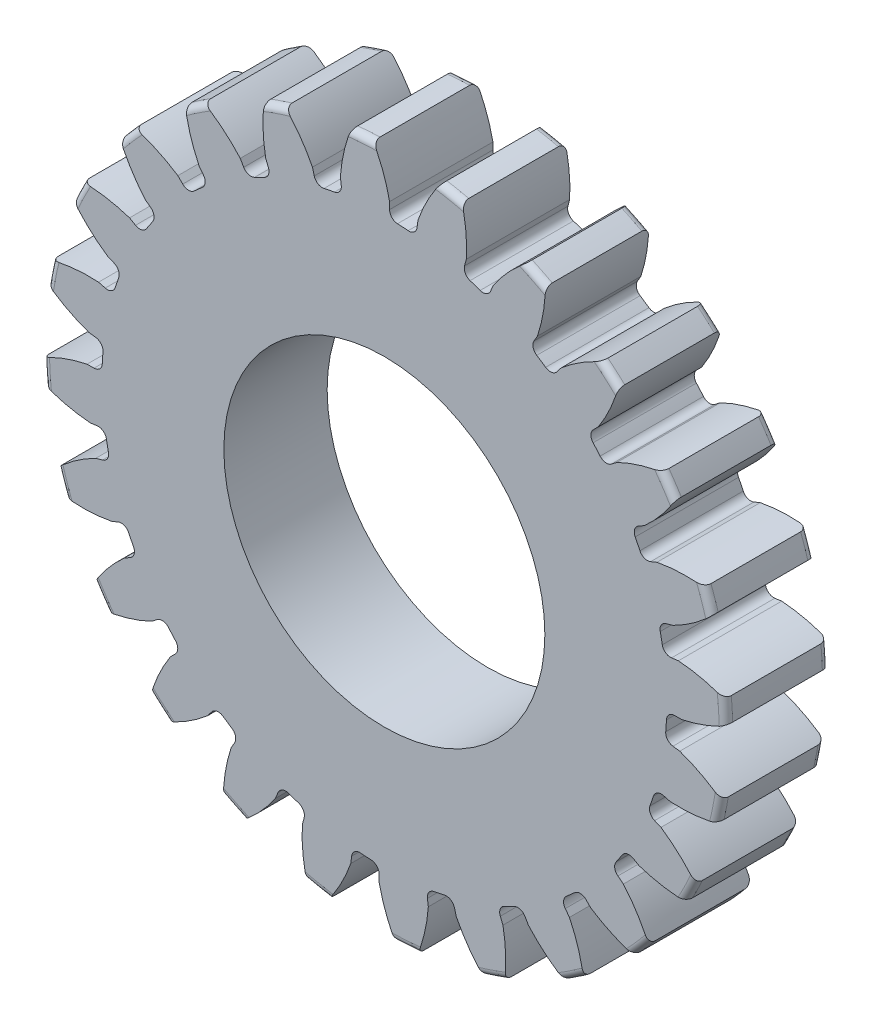
from build123d import *

# Parameters (mm, degrees)
SKETCH1_R                = 13.716
BOSS_EXTRUDE1_DEPTH      = 4.14693862
SKETCH2_W                = 6.3373
SKETCH2_H                = 6.35
FILLET2_R                = 0.27432
CUT_EXTRUDE1_DEPTH       = 23.348666063
FILLET1_R                = 0.332486
CIRPATTERN1_COUNT        = 24
FILLET1_OF_CIRPATTERN1_R = 0.332486
SKETCH5_R                = 3.175
CUT_EXTRUDE2_DEPTH       = 23.339624524
CHAMFER1_SIZE            = 0.3175
SKETCH8_W                = 6.35
SKETCH8_H                = 1.7526
CUT_SWEEP1_PITCH         = 0.79375
CUT_SWEEP1_HEIGHT        = 6.35
CUT_SWEEP1_RADIUS        = 1.7526
SKETCH12_W               = 1.7526
SKETCH12_H               = 3.175
CHAMFER3_SIZE            = 0.280416
CUT_SWEEP2_PITCH         = 0.79375
CUT_SWEEP2_HEIGHT        = 3.96875
CUT_SWEEP2_RADIUS        = 1.7526
CUT_EXTRUDE4_DEPTH       = 2.032
SKETCH19_R               = 8.586315629
CUT_EXTRUDE7_DEPTH       = 6.95286138
SKETCH20_R               = 8.250795243
CUT_EXTRUDE8_DEPTH       = 6.95286138
SKETCH21_R               = 6.442565601
CUT_EXTRUDE9_DEPTH       = 4.14693862
SCALE1_SCALE             = 1.75


with BuildPart() as part:
    # Sketch1 → Boss-Extrude1 (new body)
    with BuildSketch(Plane.XY):
        Circle(SKETCH1_R)
    extrude(amount=-BOSS_EXTRUDE1_DEPTH)

    # Fillet2
    fillet2_edges = [part.edges().sort_by_distance(p)[0] for p in [
        (-13.716, 0, 0),
        (-13.716, 0, -4.14693862),
    ]]
    fillet(fillet2_edges, radius=FILLET2_R)

    # Sketch4 → Cut-Extrude1 (cut, through all)
    with BuildSketch(Plane.XY):
        with BuildLine():
            Line((0.210191388, 11.932245124), (0.210191388, 11.33280094))
            ThreePointArc((0.210191388, 11.33280094), (0.74132985, 11.310481317), (1.27083763, 11.263282349))
            Line((1.27083763, 11.263282349), (1.349080978, 11.857598181))
            add(Edge.make_bspline(
                [(5.307200939, 15.849419331), (2.291771979, 14.546050899), (1.349080978, 11.857598181)],
                knots=[0, 0, 0, 1, 1, 1], degree=2))
            ThreePointArc((5.307200939, 15.849419331), (1.093175261, 16.67859235), (-3.193027723, 16.406555059))
            add(Edge.make_bspline(
                [(-3.193027723, 16.406555059), (-0.37352041, 14.720743801), (0.210191388, 11.932245124)],
                knots=[0, 0, 0, 1, 1, 1], degree=2))
        make_face()
    cut_extrude1 = extrude(amount=-CUT_EXTRUDE1_DEPTH, mode=Mode.SUBTRACT)

    # Fillet1
    fillet1_edges = [part.edges().sort_by_distance(p)[0] for p in [
        (1.27083763, 11.263282349, -2.07346931),
        (0.210191388, 11.33280094, -2.07346931),
    ]]
    fillet(fillet1_edges, radius=FILLET1_R)

    # CirPattern1: Cut-Extrude1 ×24 about axis
    cirpattern1_axis = Axis((0, 0, -4.14693862), (0, 0, 1))
    for i in range(1, CIRPATTERN1_COUNT):
        add(cut_extrude1.rotate(cirpattern1_axis, i * 360 / CIRPATTERN1_COUNT), mode=Mode.SUBTRACT)

    # Fillet1 of CirPattern1
    fillet1_of_cirpattern1_edges = [part.edges().sort_by_distance(p)[0] for p in [
        (-1.687617095, 11.208412292, -2.07346931),
        (-2.730115427, 11.001046646, -2.07346931),
        (-4.531063503, 10.389707459, -2.07346931),
        (-5.484369388, 9.919589204, -2.07346931),
        (-7.065725422, 8.862961233, -2.07346931),
        (-7.864872638, 8.162128151, -2.07346931),
        (-9.11886983, 6.732218846, -2.07346931),
        (-9.709397816, 5.848431552, -2.07346931),
        (-10.550578328, 4.14268687, -2.07346931),
        (-10.892243578, 3.136174008, -2.07346931),
        (-11.263282349, 1.27083763, -2.07346931),
        (-11.33280094, 0.210191388, -2.07346931),
        (-11.208412292, -1.687617095, -2.07346931),
        (-11.001046646, -2.730115427, -2.07346931),
        (-10.389707459, -4.531063503, -2.07346931),
        (-9.919589204, -5.484369388, -2.07346931),
        (-8.862961233, -7.065725422, -2.07346931),
        (-8.162128151, -7.864872638, -2.07346931),
        (-6.732218846, -9.11886983, -2.07346931),
        (-5.848431552, -9.709397816, -2.07346931),
        (-4.14268687, -10.550578328, -2.07346931),
        (-3.136174008, -10.892243578, -2.07346931),
        (-1.27083763, -11.263282349, -2.07346931),
        (-0.210191388, -11.33280094, -2.07346931),
        (1.687617095, -11.208412292, -2.07346931),
        (2.730115427, -11.001046646, -2.07346931),
        (4.531063503, -10.389707459, -2.07346931),
        (5.484369388, -9.919589204, -2.07346931),
        (7.065725422, -8.862961233, -2.07346931),
        (7.864872638, -8.162128151, -2.07346931),
        (9.11886983, -6.732218846, -2.07346931),
        (9.709397816, -5.848431552, -2.07346931),
        (10.550578328, -4.14268687, -2.07346931),
        (10.892243578, -3.136174008, -2.07346931),
        (11.263282349, -1.27083763, -2.07346931),
        (11.33280094, -0.210191388, -2.07346931),
        (11.208412292, 1.687617095, -2.07346931),
        (11.001046646, 2.730115427, -2.07346931),
        (10.389707459, 4.531063503, -2.07346931),
        (9.919589204, 5.484369388, -2.07346931),
        (8.862961233, 7.065725422, -2.07346931),
        (8.162128151, 7.864872638, -2.07346931),
        (6.732218846, 9.11886983, -2.07346931),
        (5.848431552, 9.709397816, -2.07346931),
        (4.14268687, 10.550578328, -2.07346931),
        (3.136174008, 10.892243578, -2.07346931),
    ]]
    fillet(fillet1_of_cirpattern1_edges, radius=FILLET1_OF_CIRPATTERN1_R)

    # Sketch5 → Cut-Extrude2 (cut, through all)
    with BuildSketch(Plane.XY):
        Circle(SKETCH5_R)
    extrude(amount=-CUT_EXTRUDE2_DEPTH, mode=Mode.SUBTRACT)


with BuildPart() as body_2:
    # Sketch2 → Revolve1 (revolve)
    with BuildSketch(Plane(origin=(0, 0, 0), x_dir=(0, 0, -1), z_dir=(1, 0, 0)), mode=Mode.PRIVATE) as revolve1_sk:
        with Locations((7.93115, 3.175)):
            Rectangle(SKETCH2_W, SKETCH2_H)
    revolve(revolve1_sk.sketch.rotate(Axis((0, 0, -4.7625), (0, 0, -1)), 90), axis=Axis((0, 0, -4.7625), (0, 0, -1)))

    # Chamfer1
    chamfer1_edges = [body_2.edges().sort_by_distance(p)[0] for p in [
        (-6.35, 0, -11.0998),
    ]]
    chamfer(chamfer1_edges, length=CHAMFER1_SIZE)

    # Sketch20 → Cut-Extrude8 (cut)
    with BuildSketch(Plane(origin=(0, 0, -11.0998), x_dir=(-1, 0, 0), z_dir=(0, 0, -1))):
        Circle(SKETCH20_R)
    extrude(amount=-CUT_EXTRUDE8_DEPTH, mode=Mode.SUBTRACT)


with BuildPart() as body_3:
    # Sketch8 → Revolve2 (revolve)
    with BuildSketch(Plane(origin=(0, 0, 0), x_dir=(0, -1, 0), z_dir=(1, 0, 0)), mode=Mode.PRIVATE) as revolve2_sk:
        with Locations((-3.175, 8.6487)):
            Rectangle(SKETCH8_W, SKETCH8_H)
    revolve(revolve2_sk.sketch.rotate(Axis((0, 6.35, -7.7724), (0, -1, 0)), 180), axis=Axis((0, 6.35, -7.7724), (0, -1, 0)))

    # Cut-Sweep1: sweep along a helix
    with BuildLine() as cut_sweep1_path:
        Helix(CUT_SWEEP1_PITCH, CUT_SWEEP1_HEIGHT, CUT_SWEEP1_RADIUS, center=(0, 6.35, -7.7724), direction=(0, -1, 0))
    # Sketch11 → Cut-Sweep1 (sweep, cut)
    with BuildSketch(Plane(origin=(0, 0, 0), x_dir=(0, 0, -1), z_dir=(1, 0, 0))):
        Polygon((9.525, 6.35), (9.525, 7.04453125), (9.009444252, 6.746875), (9.009444252, 6.64765625), align=None)
    sweep(path=cut_sweep1_path.line, is_frenet=True, mode=Mode.SUBTRACT)

    # Boss-Extrude2 cone 1 section (through the dimple's axis) → Boss-Extrude2 (revolve)
    with BuildSketch(Plane(origin=(0, 6.35, -7.7724), x_dir=(0, 0, 1), z_dir=(1, 0, 0))):
        Polygon((0, 0), (1.892808, 0), (0, 1.892808), align=None)
    revolve(axis=Axis((0, 6.35, -7.7724), (0, -1, 0)))


with BuildPart() as part_1:
    add(part.part)

    # Combine1: cut body 3
    add(body_3.part, mode=Mode.SUBTRACT)

    # Sketch21 → Cut-Extrude9 (cut)
    with BuildSketch(Plane(origin=(0, 0, -4.14693862), x_dir=(-1, 0, 0), z_dir=(0, 0, -1))):
        Circle(SKETCH21_R)
    extrude(amount=-CUT_EXTRUDE9_DEPTH, mode=Mode.SUBTRACT)


with BuildPart() as body_3_2:
    # Sketch12 → Revolve3 (revolve)
    with BuildSketch(Plane(origin=(0, 0, 0), x_dir=(0, 0, -1), z_dir=(1, 0, 0))):
        with Locations((9.57961, 4.7625)):
            Rectangle(SKETCH12_W, SKETCH12_H)
    revolve(axis=Axis((0, 3.175, -8.70331), (0, 1, 0)))

    # Chamfer3
    chamfer3_edges = [body_3_2.edges().sort_by_distance(p)[0] for p in [
        (0, 3.175, -6.95071),
        (0, 6.35, -6.95071),
    ]]
    chamfer(chamfer3_edges, length=CHAMFER3_SIZE)

    # Cut-Sweep2: sweep along a helix
    with BuildLine() as cut_sweep2_path:
        Helix(CUT_SWEEP2_PITCH, CUT_SWEEP2_HEIGHT, CUT_SWEEP2_RADIUS, center=(0, 6.35, -8.70331), direction=(0, -1, 0))
    # Sketch15 → Cut-Sweep2 (sweep, cut)
    with BuildSketch(Plane(origin=(0, 0, 0), x_dir=(0, 0, -1), z_dir=(1, 0, 0))):
        Polygon((10.45591, 6.35), (10.45591, 7.04453125), (9.940354252, 6.746875), (9.940354252, 6.64765625), align=None)
    sweep(path=cut_sweep2_path.line, is_frenet=True, mode=Mode.SUBTRACT)

    # Sketch16 → Cut-Extrude4 (cut)
    with BuildSketch(Plane(origin=(0, 6.35, 0), x_dir=(1, 0, 0), z_dir=(0, 1, 0))):
        Polygon((0, 9.619853552), (-0.79375, 9.161581776), (-0.79375, 8.245038224), (0, 7.786766448), (0.79375, 8.245038224), (0.79375, 9.161581776), align=None)
    extrude(amount=-CUT_EXTRUDE4_DEPTH, mode=Mode.SUBTRACT)

    # Cut-Extrude5 cone 1 section (through the dimple's axis) → Cut-Extrude5 (revolve, cut)
    with BuildSketch(Plane(origin=(0, 6.35, -8.70331), x_dir=(0, 0, 1), z_dir=(1, 0, 0))):
        Polygon((0, 0), (0.916543552, 0), (0, 0.916543552), align=None)
    revolve(axis=Axis((0, 6.35, -8.70331), (0, -1, 0)), mode=Mode.SUBTRACT)

    # Cut-Extrude6 cone 1 section (through the dimple's axis) → Cut-Extrude6 (revolve, cut)
    with BuildSketch(Plane(origin=(0, 4.318, -8.70331), x_dir=(0, 0, 1), z_dir=(1, 0, 0))):
        Polygon((0, 0), (0.79375, 0), (0, 0.458271776), align=None)
    revolve(axis=Axis((0, 4.318, -8.70331), (0, -1, 0)), mode=Mode.SUBTRACT)

    # Sketch19 → Cut-Extrude7 (cut)
    with BuildSketch(Plane(origin=(0, 0, -11.0998), x_dir=(-1, 0, 0), z_dir=(0, 0, -1))):
        Circle(SKETCH19_R)
    extrude(amount=-CUT_EXTRUDE7_DEPTH, mode=Mode.SUBTRACT)


with BuildPart() as part_2:
    # Scale1: scaled about (-1.5e-07, -3.02e-07, -2.073469314)
    add(part_1.part.scale(SCALE1_SCALE).moved(Location((1.12e-07, 2.26e-07, 1.555101985))))


solid = part_2.part
